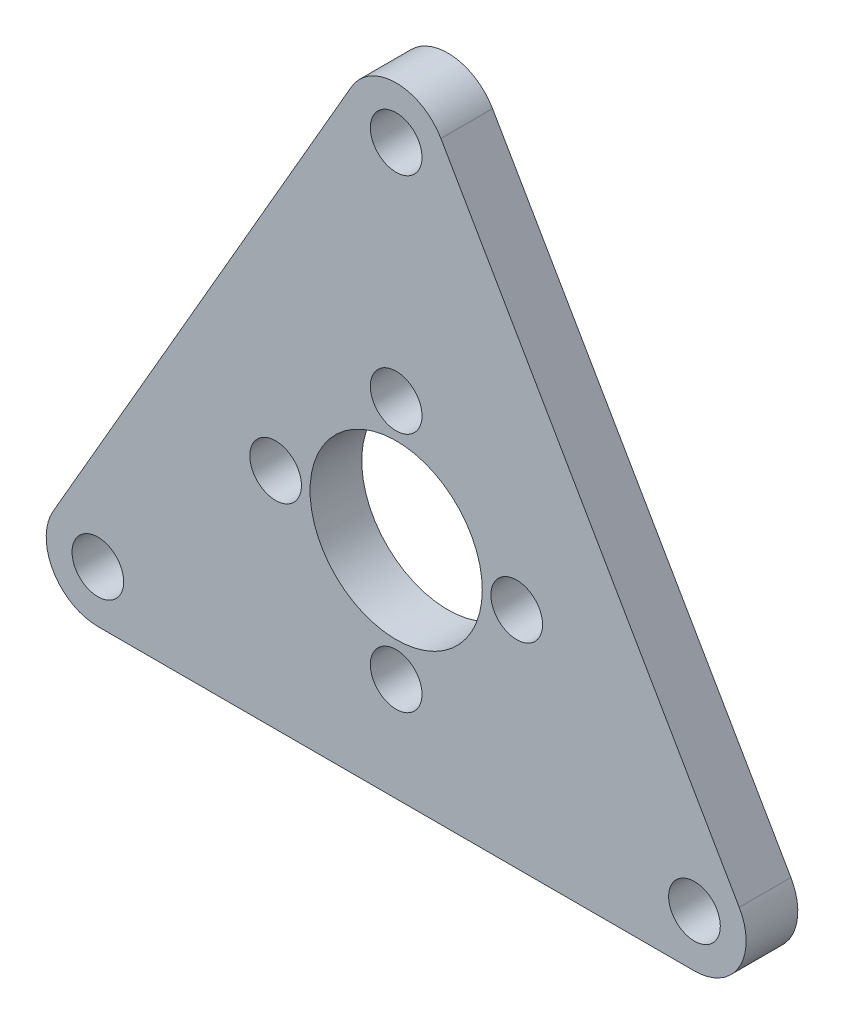
from build123d import *

# Parameters (mm, degrees)
SKETCH_1_R      = 1.5
SKETCH_1_R_2    = 5
EXTRUDE_1_DEPTH = 3


with BuildPart() as part:
    # 草图1 → 凸台-拉伸1 (new body)
    with BuildSketch(Plane.XY):
        with BuildLine():
            Line((-2.598076211, 21.5), (-19.918584287, -8.5))
            ThreePointArc((-19.918584287, -8.5), (-19.918584287, -11.5), (-17.320508076, -13))
            Line((-17.320508076, -13), (17.320508076, -13))
            ThreePointArc((17.320508076, -13), (19.918584287, -11.5), (19.918584287, -8.5))
            Line((19.918584287, -8.5), (2.598076211, 21.5))
            ThreePointArc((2.598076211, 21.5), (0, 23), (-2.598076211, 21.5))
        make_face()
        with Locations((-17.320508076, -10)):
            Circle(SKETCH_1_R, mode=Mode.SUBTRACT)
        with Locations((0, 20)):
            Circle(SKETCH_1_R, mode=Mode.SUBTRACT)
        with Locations((17.320508076, -10)):
            Circle(SKETCH_1_R, mode=Mode.SUBTRACT)
        Circle(SKETCH_1_R_2, mode=Mode.SUBTRACT)
        with Locations((0, 7)):
            Circle(SKETCH_1_R, mode=Mode.SUBTRACT)
        with Locations((0, -7)):
            Circle(SKETCH_1_R, mode=Mode.SUBTRACT)
        with Locations((-7, 0)):
            Circle(SKETCH_1_R, mode=Mode.SUBTRACT)
        with Locations((7, 0)):
            Circle(SKETCH_1_R, mode=Mode.SUBTRACT)
    extrude(amount=EXTRUDE_1_DEPTH)


solid = part.part
